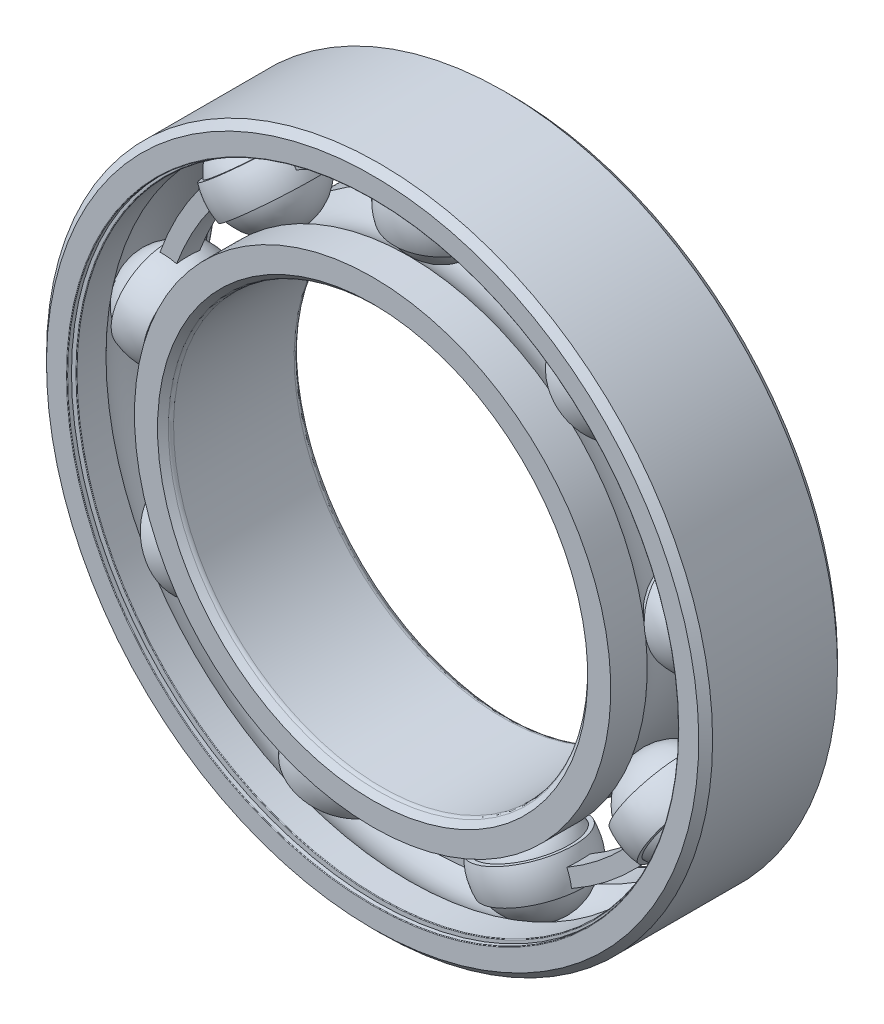
from build123d import *

# Parameters (mm, degrees)
BOSS_EXTRUDE1_DEPTH = 0.416666667
CIRPATTERN1_COUNT   = 9
CIRPATTERN2_COUNT   = 9
FILLET1_R           = 0.0225
FILLET2_R           = 0.1875


with BuildPart() as part:
    # Sketch3 → Revolve1 (revolve)
    with BuildSketch(Plane(origin=(0, 0, 0), x_dir=(0, 0, -1), z_dir=(1, 0, 0))):
        with BuildLine():
            Line((2.25, 12), (2.5, 11.75))
            Line((2.5, 11.75), (2.5, 10.919230769))
            Line((2.5, 10.919230769), (1.1875, 10.919230769))
            ThreePointArc((1.1875, 10.919230769), (0, 11.416510379), (-1.1875, 10.919230769))
            Line((-1.1875, 10.919230769), (-2.5, 10.919230769))
            Line((-2.5, 10.919230769), (-2.5, 11.75))
            Line((-2.5, 11.75), (-2.25, 12))
            Line((-2.25, 12), (2.25, 12))
        make_face()
    revolve(axis=Axis((0, 0, 2.5), (0, 0, -1)))

    # Sketch8 → Cut-Revolve1 (revolve, cut)
    with BuildSketch(Plane(origin=(0, 0, 0), x_dir=(0, 0, -1), z_dir=(1, 0, 0))):
        Polygon((-2.34, 10.919230769), (-2.25, 10.919230769), (-2.25, 11.279487179), (-2.34, 11.279487179), (-2.34, 11.009230769), (-2.5, 11.009230769), (-2.5, 10.919230769), align=None)
        Polygon((2.25, 10.919230769), (2.34, 10.919230769), (2.5, 10.919230769), (2.5, 11.009230769), (2.34, 11.009230769), (2.34, 11.279487179), (2.25, 11.279487179), align=None)
    revolve(axis=Axis((0, 0, 2.5), (0, 0, -1)), mode=Mode.SUBTRACT)

    # Fillet1
    fillet1_edges = [part.edges().sort_by_distance(p)[0] for p in [
        (0, -10.919230769, -2.25),
        (0, -11.009230769, -2.5),
        (0, -10.919230769, 2.25),
        (0, -11.009230769, 2.5),
    ]]
    fillet(fillet1_edges, radius=FILLET1_R)


with BuildPart() as body_2:
    # Sketch4 → Revolve2 (revolve)
    with BuildSketch(Plane(origin=(0, 0, 0), x_dir=(0, 0, -1), z_dir=(1, 0, 0))):
        with BuildLine():
            Line((-2.25, 7.5), (-2.5, 7.75))
            Line((-2.5, 7.75), (-2.5, 8.580769231))
            Line((-2.5, 8.580769231), (-1.1875, 8.580769231))
            ThreePointArc((-1.1875, 8.580769231), (0, 8.083489621), (1.1875, 8.580769231))
            Line((1.1875, 8.580769231), (2.5, 8.580769231))
            Line((2.5, 8.580769231), (2.5, 7.75))
            Line((2.5, 7.75), (2.25, 7.5))
            Line((2.25, 7.5), (-2.25, 7.5))
        make_face()
    revolve(axis=Axis((0, 0, 2.5), (0, 0, -1)))

    # Fillet2
    fillet2_edges = [body_2.edges().sort_by_distance(p)[0] for p in [
        (0, -7.5, -2.25),
        (0, -7.5, 2.25),
    ]]
    fillet(fillet2_edges, radius=FILLET2_R)


with BuildPart() as body_3:
    # Sketch5 → Revolve3 (revolve)
    with BuildSketch(Plane(origin=(0, 0, 0), x_dir=(0, 0, -1), z_dir=(1, 0, 0))):
        with BuildLine():
            Line((-1.666510379, 9.75), (1.666510379, 9.75))
            ThreePointArc((1.666510379, 9.75), (0, 11.416510379), (-1.666510379, 9.75))
        make_face()
    revolve(axis=Axis((0, 9.75, 1.666510379), (0, 0, -1)))


with BuildPart() as body_4:
    # Sketch6 → Revolve4 (revolve)
    with BuildSketch(Plane(origin=(0, 0, 0), x_dir=(0, 0, -1), z_dir=(1, 0, 0))):
        with BuildLine():
            Line((-1.56060299, 10.334615385), (-1.717169159, 10.334615385))
            ThreePointArc((-1.717169159, 10.334615385), (-1.795452243, 9.75), (-1.717169159, 9.165384615))
            Line((-1.717169159, 9.165384615), (-1.56060299, 9.165384615))
            ThreePointArc((-1.56060299, 9.165384615), (-1.666510379, 9.75), (-1.56060299, 10.334615385))
        make_face()
    revolve4 = revolve(axis=Axis((0, 12, 0), (0, -1, 0)))

    # Sketch7 → Boss-Extrude1 (add, symmetric)
    with BuildSketch(Plane.XY):
        with BuildLine():
            Line((6.267179194, 7.46893332), (6.64296272, 7.916774687))
            ThreePointArc((6.64296272, 7.916774687), (3.534646635, 9.711361816), (0, 10.334615385))
            Line((0, 10.334615385), (0, 9.75))
            ThreePointArc((0, 9.75), (3.334696397, 9.162003053), (6.267179194, 7.46893332))
        make_face()
    boss_extrude1 = extrude(amount=BOSS_EXTRUDE1_DEPTH, both=True)

    # CirPattern2: Revolve4, Boss-Extrude1 ×9 about axis
    cirpattern2_axis = Axis((0, 0, 2.5), (0, 0, -1))
    add([revolve4.rotate(cirpattern2_axis, i * 360 / CIRPATTERN2_COUNT) for i in range(1, CIRPATTERN2_COUNT)])
    add([boss_extrude1.rotate(cirpattern2_axis, i * 360 / CIRPATTERN2_COUNT) for i in range(1, CIRPATTERN2_COUNT)])


with BuildPart() as cirpattern1_1:
    # CirPattern1: pattern copy
    add(body_3.part.rotate(Axis((0, 0, 2.5), (0, 0, -1)), 1 * 360 / CIRPATTERN1_COUNT))


with BuildPart() as cirpattern1_2:
    # CirPattern1: pattern copy
    add(body_3.part.rotate(Axis((0, 0, 2.5), (0, 0, -1)), 2 * 360 / CIRPATTERN1_COUNT))


with BuildPart() as cirpattern1_3:
    # CirPattern1: pattern copy
    add(body_3.part.rotate(Axis((0, 0, 2.5), (0, 0, -1)), 3 * 360 / CIRPATTERN1_COUNT))


with BuildPart() as cirpattern1_4:
    # CirPattern1: pattern copy
    add(body_3.part.rotate(Axis((0, 0, 2.5), (0, 0, -1)), 4 * 360 / CIRPATTERN1_COUNT))


with BuildPart() as cirpattern1_5:
    # CirPattern1: pattern copy
    add(body_3.part.rotate(Axis((0, 0, 2.5), (0, 0, -1)), 5 * 360 / CIRPATTERN1_COUNT))


with BuildPart() as cirpattern1_6:
    # CirPattern1: pattern copy
    add(body_3.part.rotate(Axis((0, 0, 2.5), (0, 0, -1)), 6 * 360 / CIRPATTERN1_COUNT))


with BuildPart() as cirpattern1_7:
    # CirPattern1: pattern copy
    add(body_3.part.rotate(Axis((0, 0, 2.5), (0, 0, -1)), 7 * 360 / CIRPATTERN1_COUNT))


with BuildPart() as cirpattern1_8:
    # CirPattern1: pattern copy
    add(body_3.part.rotate(Axis((0, 0, 2.5), (0, 0, -1)), 8 * 360 / CIRPATTERN1_COUNT))


solid = Compound([part.part, body_2.part, body_3.part, body_4.part, cirpattern1_1.part, cirpattern1_2.part, cirpattern1_3.part, cirpattern1_4.part, cirpattern1_5.part, cirpattern1_6.part, cirpattern1_7.part, cirpattern1_8.part])
